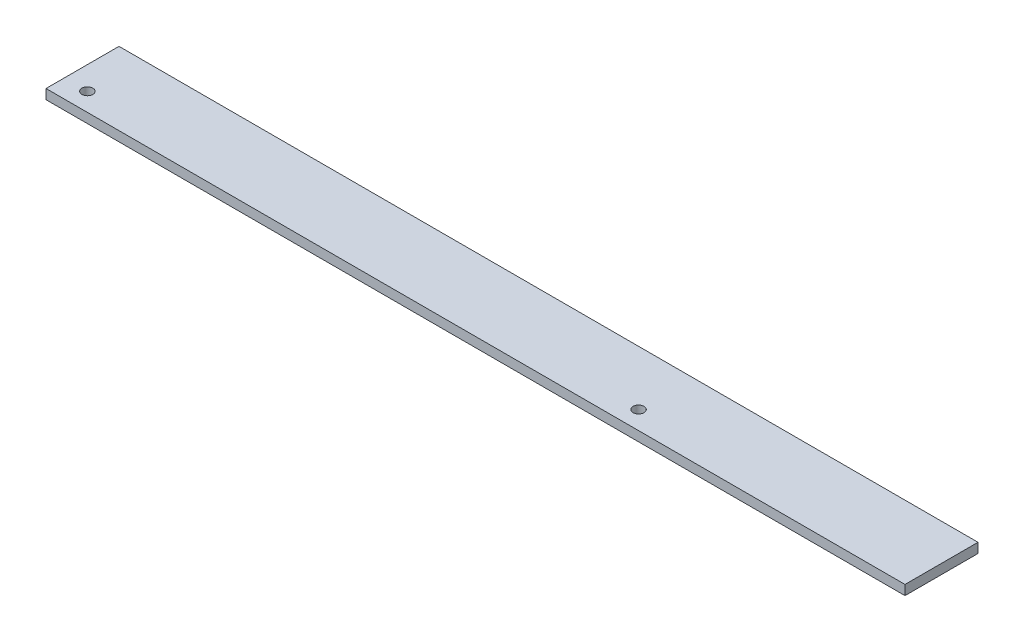
from build123d import *

# Parameters (mm, degrees)
SKETCH_1_W          = 30
SKETCH_1_H          = 4
EXTRUDE_1_DEPTH     = 353
SKETCH_2_R          = 2.25
CUT_EXTRUDE_1_DEPTH = 5


with BuildPart() as part:
    # Эскиз1 → Бобышка-Вытянуть1 (new body)
    with BuildSketch(Plane(origin=(0, 0, 0), x_dir=(0, 0, -1), z_dir=(1, 0, 0))):
        Rectangle(SKETCH_1_W, SKETCH_1_H)
    extrude(amount=EXTRUDE_1_DEPTH)

    # Эскиз2 → Вырез-Вытянуть1 (cut, through all)
    with BuildSketch(Plane(origin=(0, 2, 0), x_dir=(1, 0, 0), z_dir=(0, 1, 0))):
        with Locations((9.5, -7.5)):
            Circle(SKETCH_2_R)
        with Locations((236, -7.5)):
            Circle(SKETCH_2_R)
    extrude(amount=-CUT_EXTRUDE_1_DEPTH, mode=Mode.SUBTRACT)


solid = part.part
